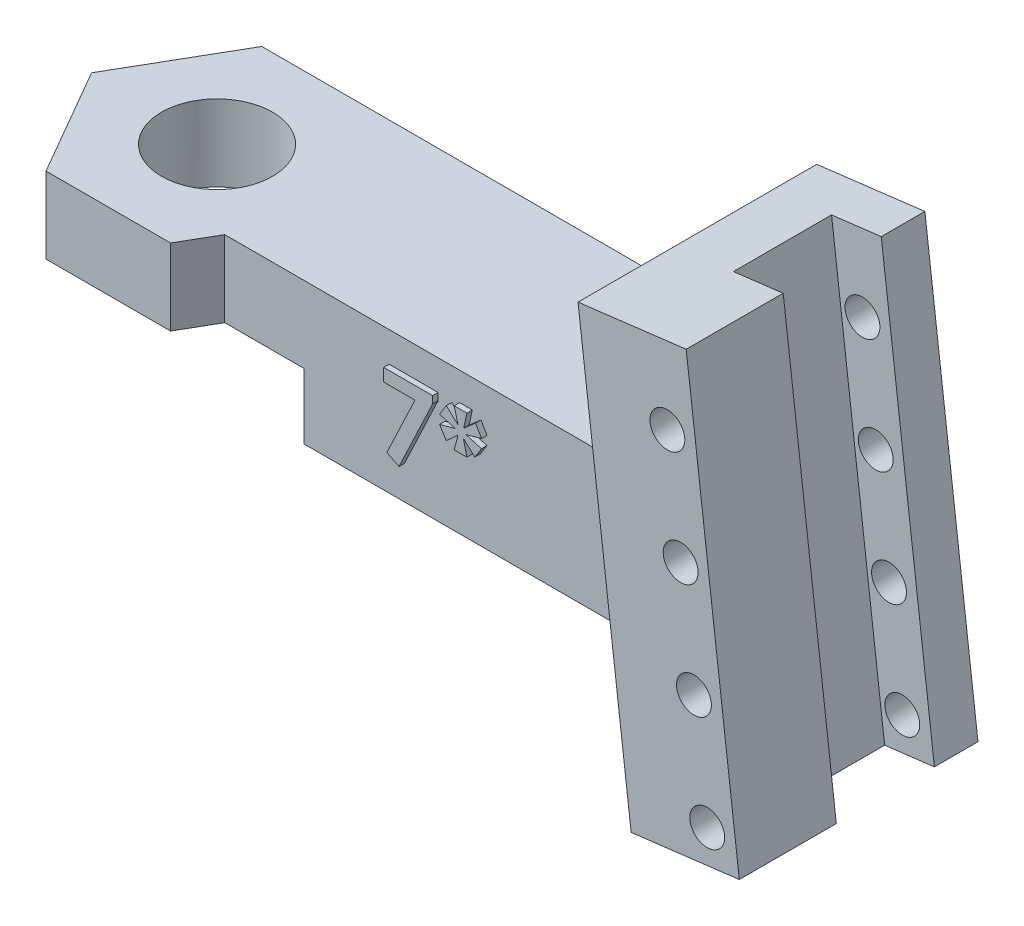
from build123d import *

# Parameters (mm, degrees)
SKETCH1_W                = 25
SKETCH1_H                = 6.75
BOSS_EXTRUDE1_DEPTH      = 6.5
BOSS_EXTRUDE4_DEPTH      = 6.5
BOSS_EXTRUDE3_DEPTH      = 6
BOSS_EXTRUDE3_DEPTH_BACK = 4.95
SKETCH4_W                = 2.3
SKETCH4_H                = 4.5
CUT_EXTRUDE1_DEPTH       = 23
SKETCH6_R                = 2.55
CUT_EXTRUDE2_DEPTH       = 10
BOSS_EXTRUDE5_DEPTH      = 1.575
CUT_EXTRUDE3_DEPTH       = 3
SKETCH9_R                = 0.8
CUT_EXTRUDE4_DEPTH       = 10.95
BOSS_EXTRUDE6_DEPTH      = 0.25


with BuildPart() as part:
    # Sketch1 → Boss-Extrude1 (new body)
    with BuildSketch(Plane(origin=(0, 0, 0), x_dir=(1, 0, 0), z_dir=(0, 1, 0))):
        with Locations((12.5, -3.375)):
            Rectangle(SKETCH1_W, SKETCH1_H)
    extrude(amount=BOSS_EXTRUDE1_DEPTH)

    # Sketch5 → Boss-Extrude4 (add)
    with BuildSketch(Plane(origin=(0, 6.5, 0), x_dir=(1, 0, 0), z_dir=(0, 1, 0))):
        Polygon((-5.715767665, -3.375), (-2.857883832, -8.325), (2.857883832, -8.325), (5.715767665, -3.375), (2.857883832, 1.575), (-2.857883832, 1.575), align=None)
    extrude(amount=-BOSS_EXTRUDE4_DEPTH)

    # Sketch3 → Boss-Extrude3 (add, two sides)
    with BuildSketch(Plane.XY.offset(3.375)) as boss_extrude3_sk:
        Polygon((22.599882374, 14.546249674), (27.562613132, 15.155596391), (30, -4.695326641), (25.037269242, -5.304673359), align=None)
    extrude(amount=BOSS_EXTRUDE3_DEPTH)
    extrude(boss_extrude3_sk.sketch, amount=-BOSS_EXTRUDE3_DEPTH_BACK)

    # Sketch4 → Cut-Extrude1 (cut)
    with BuildSketch(Plane(origin=(-1.423871601, 11.596503591, 0), x_dir=(0.992546152, 0.121869343, 0), z_dir=(-0.121869343, 0.992546152, 0))):
        with Locations((28.054168174, -2.675)):
            Rectangle(SKETCH4_W, SKETCH4_H)
    extrude(amount=-CUT_EXTRUDE1_DEPTH, mode=Mode.SUBTRACT)

    # Sketch6 → Cut-Extrude2 (cut)
    with BuildSketch(Plane(origin=(0, 6.5, 0), x_dir=(1, 0, 0), z_dir=(0, 1, 0))):
        with Locations((0, -3.335615973)):
            Circle(SKETCH6_R)
    extrude(amount=-CUT_EXTRUDE2_DEPTH, mode=Mode.SUBTRACT)

    # Sketch7 → Boss-Extrude5 (add)
    with BuildSketch(Plane(origin=(0, 0, -1.575), x_dir=(-1, 0, 0), z_dir=(0, 0, -1))):
        Polygon((-2.857883832, 0), (-24.385937253, 0), (-25.037269242, -5.304673359), (-30, -4.695326641), (-27.562613132, 15.155596391), (-22.599882374, 14.546249674), (-23.587837607, 6.5), (-2.857883832, 6.5), align=None)
    extrude(amount=-BOSS_EXTRUDE5_DEPTH)

    # Sketch8 → Cut-Extrude3 (cut)
    with BuildSketch(Plane(origin=(0, 0, 0), x_dir=(-1, 0, 0), z_dir=(0, -1, 0))):
        Polygon((-4.67653718, -11.475), (4.67653718, -11.475), (9.353074361, -3.375), (4.67653718, 4.725), (-4.67653718, 4.725), (-9.353074361, -3.375), align=None)
    extrude(amount=-CUT_EXTRUDE3_DEPTH, mode=Mode.SUBTRACT)

    # Sketch9 → Cut-Extrude4 (cut)
    with BuildSketch(Plane(origin=(0, 0, -1.575), x_dir=(-1, 0, 0), z_dir=(0, 0, -1))):
        with Locations((-28.526885988, -3.36493756)):
            Circle(SKETCH9_R)
        with Locations((-27.917539271, 1.597793198)):
            Circle(SKETCH9_R)
        with Locations((-27.308192554, 6.560523956)):
            Circle(SKETCH9_R)
        with Locations((-26.698845837, 11.523254714)):
            Circle(SKETCH9_R)
    extrude(amount=-CUT_EXTRUDE4_DEPTH, mode=Mode.SUBTRACT)

    # Sketch10 → Boss-Extrude6 (add)
    with BuildSketch(Plane.XY.offset(6.75)):
        Polygon((11.311801843, 5.121255448), (13.555391587, 5.121255448), (13.555391587, 4.795233814), (12.011521395, 1.531511859), (11.454830689, 1.811960577), (12.744894792, 4.537922115), (11.311801843, 4.537922115), align=None)
        Polygon((14.542571074, 5.210999038), (15.125904407, 5.210999038), (14.980071074, 4.537922115), (15.523440465, 5.013983814), (15.798981331, 4.537922115), (15.081032613, 4.335999038), (15.798981331, 4.134075961), (15.488384375, 3.647497435), (14.961841907, 4.134075961), (15.125904407, 3.460999038), (14.542571074, 3.460999038), (14.719954888, 4.134075961), (14.18149335, 3.647497435), (13.869494151, 4.134075961), (14.587442869, 4.335999038), (13.869494151, 4.537922115), (14.18149335, 5.036419711), (14.719954888, 4.537922115), align=None)
    extrude(amount=BOSS_EXTRUDE6_DEPTH)


solid = part.part
